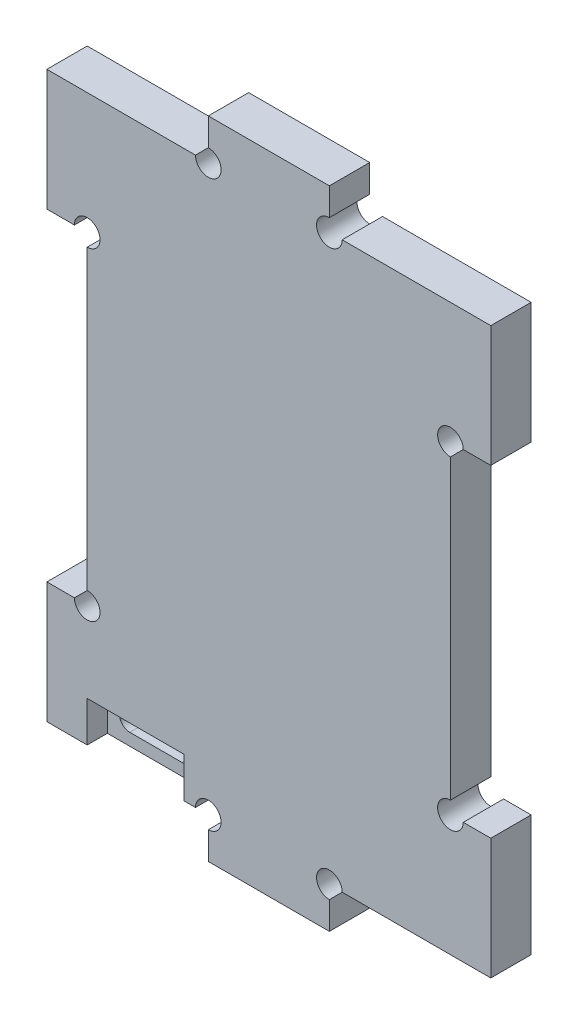
from build123d import *

# Parameters (mm, degrees)
BOSS_EXTRUDE2_DEPTH = 5
SKETCH3_W           = 5
SKETCH3_H           = 40
CUT_EXTRUDE1_DEPTH  = 5
SKETCH5_W           = 12
SKETCH5_H           = 5
CUT_EXTRUDE2_DEPTH  = 2.5
CUT_EXTRUDE3_DEPTH  = 3.5
SKETCH7_R           = 1.5875
CUT_EXTRUDE4_DEPTH  = 6


with BuildPart() as part:
    # Sketch2 → Boss-Extrude2 (new body)
    with BuildSketch(Plane.XY):
        Polygon((-7.5, 40), (7.5, 40), (7.5, 35), (27.5, 35), (27.5, -35), (7.5, -35), (7.5, -40), (-7.5, -40), (-7.5, -35), (-27.5, -35), (-27.5, 35), (-7.5, 35), align=None)
    extrude(amount=BOSS_EXTRUDE2_DEPTH)

    # Sketch3 → Cut-Extrude1 (cut)
    with BuildSketch(Plane.XY.offset(5)):
        with Locations((-25, 0)):
            Rectangle(SKETCH3_W, SKETCH3_H)
    cut_extrude1 = extrude(amount=-CUT_EXTRUDE1_DEPTH, mode=Mode.SUBTRACT)

    # Mirror1: Cut-Extrude1 across plane
    add(cut_extrude1.mirror(Plane(origin=(0, 0, 0), x_dir=(0, 0, 1), z_dir=(1, 0, 0))), mode=Mode.SUBTRACT)

    # Sketch5 → Cut-Extrude2 (cut)
    with BuildSketch(Plane.XY.offset(5)):
        with Locations((-16.5, -32.5)):
            Rectangle(SKETCH5_W, SKETCH5_H)
    extrude(amount=-CUT_EXTRUDE2_DEPTH, mode=Mode.SUBTRACT)

    # Sketch6 → Cut-Extrude3 (cut, through all)
    with BuildSketch(Plane.XY.offset(2.5)):
        with BuildLine():
            Line((-19.72, -33.5), (-13.28, -33.5))
            ThreePointArc((-13.28, -33.5), (-12.37490332, -33.12509668), (-12, -32.22))
            Line((-12, -32.22), (-12, -31.58))
            ThreePointArc((-12, -31.58), (-12.37490332, -30.67490332), (-13.28, -30.3))
            Line((-13.28, -30.3), (-19.72, -30.3))
            ThreePointArc((-19.72, -30.3), (-20.62509668, -30.67490332), (-21, -31.58))
            Line((-21, -31.58), (-21, -32.22))
            ThreePointArc((-21, -32.22), (-20.62509668, -33.12509668), (-19.72, -33.5))
        make_face()
    extrude(amount=-CUT_EXTRUDE3_DEPTH, mode=Mode.SUBTRACT)

    # Sketch7 → Cut-Extrude4 (cut, through all)
    with BuildSketch(Plane.XY.offset(5)):
        with Locations((-7.5, 35)):
            Circle(SKETCH7_R)
        with Locations((7.5, 35)):
            Circle(SKETCH7_R)
        with Locations((22.5, 20)):
            Circle(SKETCH7_R)
        with Locations((-22.5, 20)):
            Circle(SKETCH7_R)
        with Locations((-22.5, -20)):
            Circle(SKETCH7_R)
        with Locations((-7.5, -35)):
            Circle(SKETCH7_R)
        with Locations((7.5, -35)):
            Circle(SKETCH7_R)
        with Locations((22.5, -20)):
            Circle(SKETCH7_R)
    extrude(amount=-CUT_EXTRUDE4_DEPTH, mode=Mode.SUBTRACT)


solid = part.part
